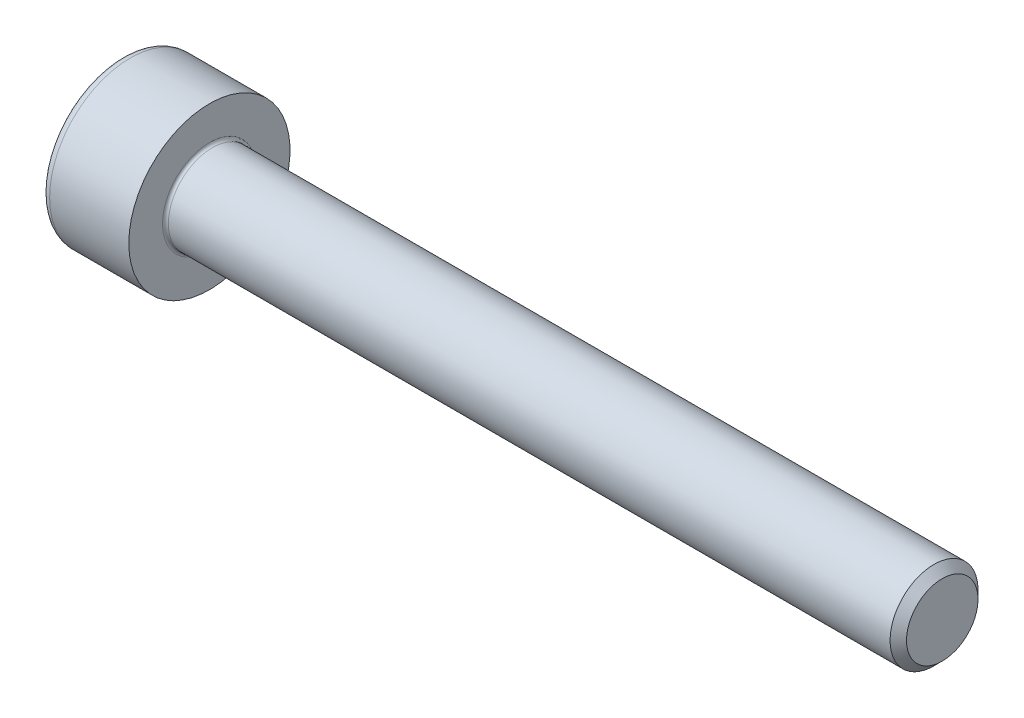
from build123d import *

# Parameters (mm, degrees)
FILLET1_R   = 0.1
FILLET2_R   = 0.3
HEX_2_DEPTH = 1.3


with BuildPart() as part:
    # BodySke → Base-Revolve (revolve)
    with BuildSketch(Plane.XY):
        Polygon((0, 0), (0, 2.75), (3, 2.75), (3, 1.5), (27.7195, 1.5), (28, 1.2195), (28, 0), align=None)
    revolve(axis=Axis((-31.75, 0, 0), (1, 0, 0)))

    # Fillet1
    fillet1_edges = [part.edges().sort_by_distance(p)[0] for p in [
        (3, -1.5, 0),
    ]]
    fillet(fillet1_edges, radius=FILLET1_R)

    # Fillet2
    fillet2_edges = [part.edges().sort_by_distance(p)[0] for p in [
        (0, -2.75, 0),
    ]]
    fillet(fillet2_edges, radius=FILLET2_R)

    # Sketch2 → Hex-PreBroach (revolve, cut)
    with BuildSketch(Plane.XY):
        Polygon((0, 1.26), (1.3, 1.26), (2.027461339, 0), (0, 0), align=None)
    revolve(axis=Axis((0, 0, 0), (1, 0, 0)), mode=Mode.SUBTRACT)

    # Sketch3 → Hex 2 (cut)
    with BuildSketch(Plane(origin=(0, 0, 0), x_dir=(0, 0.5, 0.866025404), z_dir=(-1, 0, 0))):
        Polygon((0.727461339, 1.26), (-0.727461339, 1.26), (-1.454922678, 0), (-0.727461339, -1.26), (0.727461339, -1.26), (1.454922678, 0), align=None)
    extrude(amount=-HEX_2_DEPTH, mode=Mode.SUBTRACT)


solid = part.part
